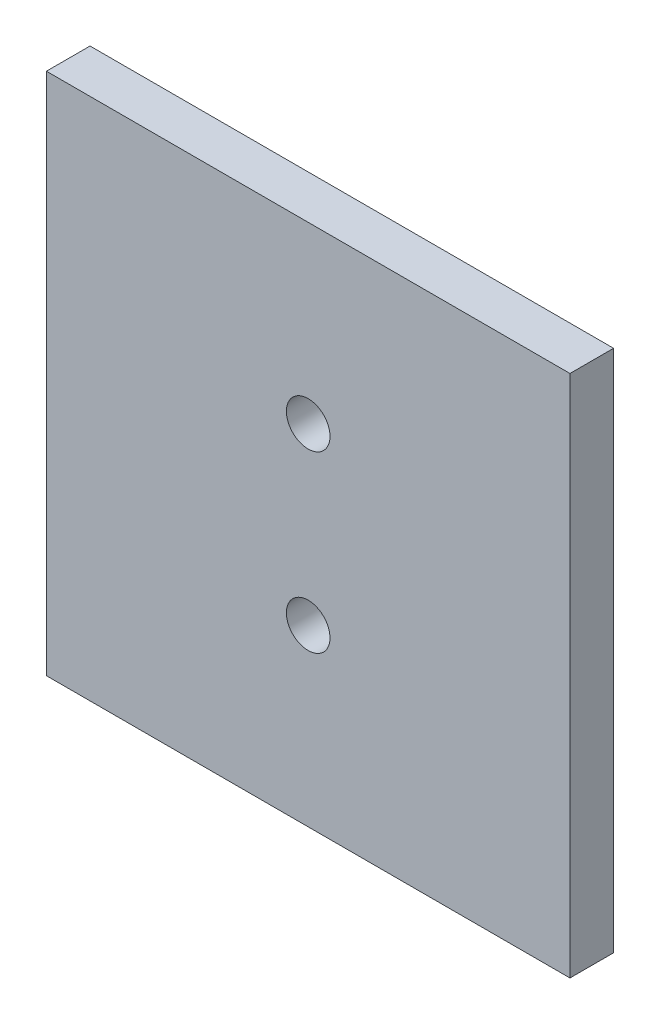
from build123d import *

# Parameters (mm, degrees)
SKETCH1_W           = 76.2
SKETCH1_H           = 76.2
SKETCH1_R           = 3.175
BOSS_EXTRUDE1_DEPTH = 6.35


with BuildPart() as part:
    # Sketch1 → Boss-Extrude1 (new body)
    with BuildSketch(Plane.XY):
        with Locations((38.1, 38.1)):
            Rectangle(SKETCH1_W, SKETCH1_H)
        with Locations((38.1, 50.8)):
            Circle(SKETCH1_R, mode=Mode.SUBTRACT)
        with Locations((38.1, 25.4)):
            Circle(SKETCH1_R, mode=Mode.SUBTRACT)
    extrude(amount=BOSS_EXTRUDE1_DEPTH)


solid = part.part
